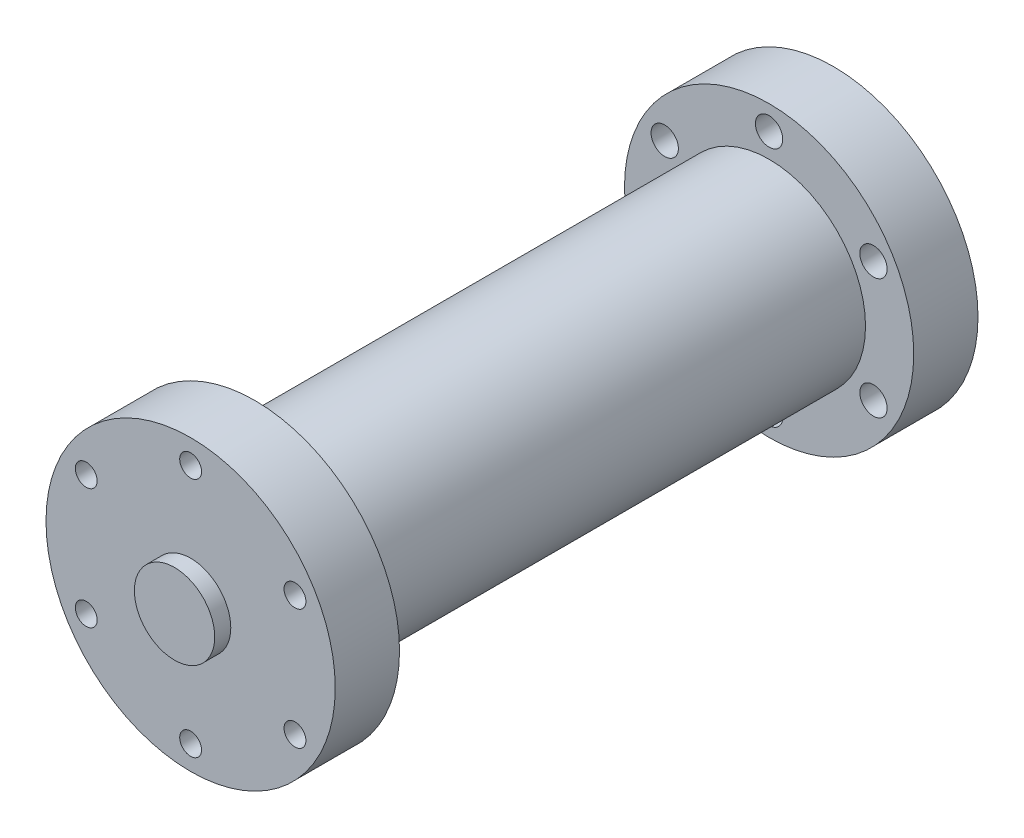
from build123d import *

# Parameters (mm, degrees)
SKETCH1_R                      = 45
BOSS_EXTRUDE1_DEPTH            = 20
SKETCH2_R                      = 30
BOSS_EXTRUDE2_DEPTH            = 160
SKETCH3_R                      = 45
BOSS_EXTRUDE3_DEPTH            = 20
SKETCH4_R                      = 12.5
BOSS_EXTRUDE4_DEPTH            = 5
M8X1_25_TAPPED_HOLE1_REACH     = 202
M8X1_25_TAPPED_HOLE1_BORE_R    = 3.4
CIRPATTERN1_COUNT              = 6
F_8_5_8_5_DIAMETER_HOLE1_D     = 8.5
F_8_5_8_5_DIAMETER_HOLE1_DEPTH = 20.001
CIRPATTERN2_COUNT              = 6
SKETCH11_R                     = 12.5
CUT_EXTRUDE1_DEPTH             = 20


with BuildPart() as part:
    # Sketch1 → Boss-Extrude1 (new body)
    with BuildSketch(Plane.XY):
        Circle(SKETCH1_R)
    extrude(amount=BOSS_EXTRUDE1_DEPTH)

    # Sketch2 → Boss-Extrude2 (add)
    with BuildSketch(Plane(origin=(0, 0, 0), x_dir=(-1, 0, 0), z_dir=(0, 0, -1))):
        Circle(SKETCH2_R)
    extrude(amount=BOSS_EXTRUDE2_DEPTH)

    # Sketch3 → Boss-Extrude3 (add)
    with BuildSketch(Plane(origin=(0, 0, -160), x_dir=(-1, 0, 0), z_dir=(0, 0, -1))):
        with Locations(Location((0, 0, 0), (0, 0, 180))):  # turned: the seam where the file's is
            Circle(SKETCH3_R)
    extrude(amount=BOSS_EXTRUDE3_DEPTH)

    # Sketch4 → Boss-Extrude4 (add)
    with BuildSketch(Plane.XY.offset(20)):
        Circle(SKETCH4_R)
    extrude(amount=BOSS_EXTRUDE4_DEPTH)

    # M8x1.25 Tapped Hole1 bore → M8x1.25 Tapped Hole1 (cut, up to next)
    with BuildSketch(Plane.XY.offset(20), mode=Mode.PRIVATE) as m8x1_25_tapped_hole1_sk1:
        with Locations((0, 37.5)):
            Circle(M8X1_25_TAPPED_HOLE1_BORE_R)
    m8x1_25_tapped_hole1_tool1 = extrude(m8x1_25_tapped_hole1_sk1.sketch, amount=-M8X1_25_TAPPED_HOLE1_REACH, mode=Mode.PRIVATE) & part.part
    m8x1_25_tapped_hole1 = m8x1_25_tapped_hole1_tool1.solids().sort_by_distance((0, 37.5, 20))[0]
    add(m8x1_25_tapped_hole1, mode=Mode.SUBTRACT)

    # CirPattern1: M8x1.25 Tapped Hole1 ×6 about axis
    cirpattern1_axis = Axis((0, 0, 0), (0, 0, 1))
    for i in range(1, CIRPATTERN1_COUNT):
        add(m8x1_25_tapped_hole1.rotate(cirpattern1_axis, i * 360 / CIRPATTERN1_COUNT), mode=Mode.SUBTRACT)

    # Ø8.5 (8.5) Diameter Hole1
    with Locations(Plane(origin=(0, 0, -180), x_dir=(-1, 0, 0), z_dir=(0, 0, -1))):
        with Locations((0, 37.5)):
            f_8_5_8_5_diameter_hole1 = Hole(F_8_5_8_5_DIAMETER_HOLE1_D / 2, depth=F_8_5_8_5_DIAMETER_HOLE1_DEPTH)

    # CirPattern2: Ø8.5 (8.5) Diameter Hole1 ×6 about axis
    cirpattern2_axis = Axis((0, 0, 0), (0, 0, 1))
    for i in range(1, CIRPATTERN2_COUNT):
        add(f_8_5_8_5_diameter_hole1.rotate(cirpattern2_axis, i * 360 / CIRPATTERN2_COUNT), mode=Mode.SUBTRACT)

    # Sketch11 → Cut-Extrude1 (cut)
    with BuildSketch(Plane(origin=(0, 0, -180), x_dir=(-1, 0, 0), z_dir=(0, 0, -1))):
        with Locations(Location((0, 0, 0), (0, 0, 180))):  # turned: the seam where the file's is
            Circle(SKETCH11_R)
    extrude(amount=-CUT_EXTRUDE1_DEPTH, mode=Mode.SUBTRACT)


solid = part.part
